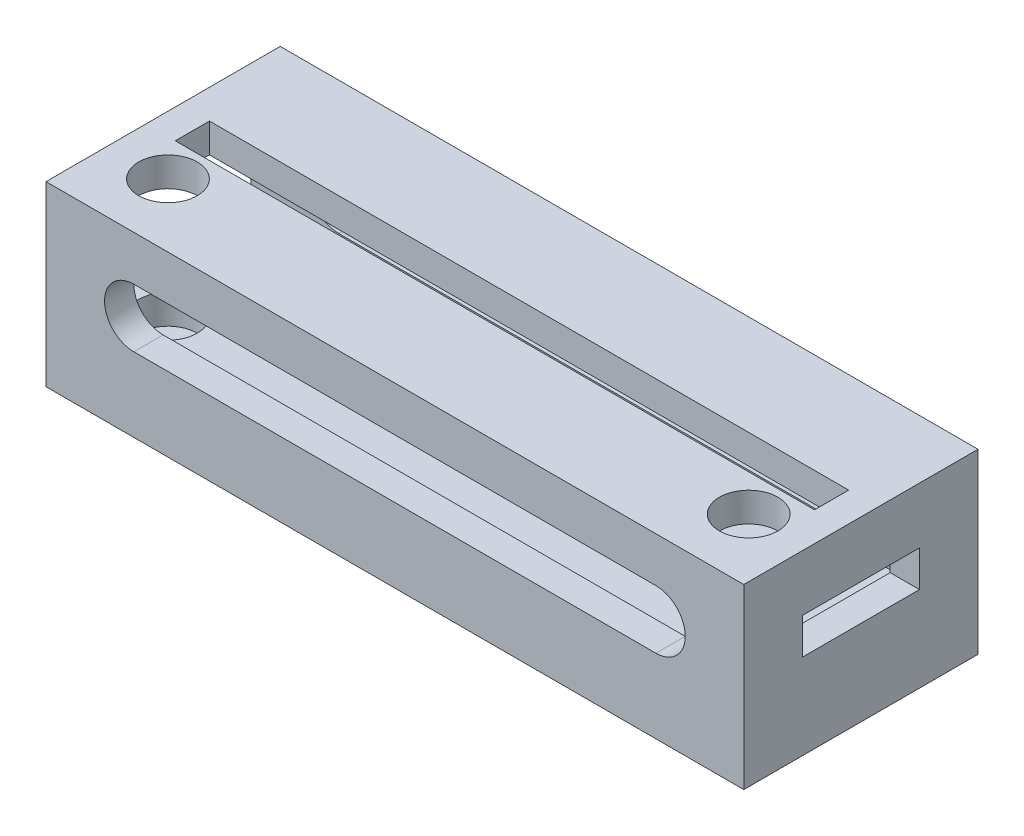
from build123d import *

# Parameters (mm, degrees)
SKETCH1_W            = 65.5
SKETCH1_H            = 9
SKETCH1_R            = 0.998395378
SKETCH1_R_2          = 1.243115981
BOSS_EXTRUDE1_DEPTH  = 6
SKETCH3_W            = 65.5
SKETCH3_H            = 6
BOSS_EXTRUDE2_DEPTH  = 10
SKETCH4_W            = 65.5
SKETCH4_H            = 6
BOSS_EXTRUDE3_DEPTH  = 2
SKETCH5_W            = 65.5
SKETCH5_H            = 3
BOSS_EXTRUDE4_DEPTH  = 9.2
SKETCH7_W            = 21
SKETCH7_H            = 15.2
BOSS_EXTRUDE6_DEPTH  = 3
SKETCH12_W           = 68.5
SKETCH12_H           = 15.2
BOSS_EXTRUDE10_DEPTH = 3
SKETCH13_W           = 24
SKETCH13_H           = 15.2
SKETCH13_W_2         = 12
SKETCH13_H_2         = 3.7
BOSS_EXTRUDE11_DEPTH = 3
CUT_EXTRUDE2_DEPTH   = 25
SKETCH11_W           = 18
SKETCH11_H           = 9.2
CUT_EXTRUDE4_DEPTH   = 3
SKETCH14_W           = 71.5
SKETCH14_H           = 24
BOSS_EXTRUDE12_DEPTH = 3
SKETCH15_W           = 65.5
SKETCH15_H           = 3.5
CUT_EXTRUDE5_DEPTH   = 3
SKETCH16_R           = 3
CUT_EXTRUDE6_DEPTH   = 15.2


with BuildPart() as part:
    # Sketch1 → Boss-Extrude1 (new body)
    with BuildSketch(Plane(origin=(0, 0, 0), x_dir=(1, 0, 0), z_dir=(0, 1, 0))):
        Rectangle(SKETCH1_W, SKETCH1_H)
        with Locations((-29.75, 0)):
            Circle(SKETCH1_R, mode=Mode.SUBTRACT)
        with Locations((29.75, 0)):
            Circle(SKETCH1_R_2, mode=Mode.SUBTRACT)
    extrude(amount=BOSS_EXTRUDE1_DEPTH)

    # Sketch3 → Boss-Extrude2 (add)
    with BuildSketch(Plane(origin=(0, 0, -4.5), x_dir=(-1, 0, 0), z_dir=(0, 0, -1))):
        with Locations((0, 3)):
            Rectangle(SKETCH3_W, SKETCH3_H)
    extrude(amount=BOSS_EXTRUDE2_DEPTH)

    # Sketch4 → Boss-Extrude3 (add)
    with BuildSketch(Plane.XY.offset(4.5)):
        with Locations((0, 3)):
            Rectangle(SKETCH4_W, SKETCH4_H)
    extrude(amount=BOSS_EXTRUDE3_DEPTH)

    # Sketch5 → Boss-Extrude4 (add)
    with BuildSketch(Plane(origin=(0, 6, 0), x_dir=(1, 0, 0), z_dir=(0, 1, 0))):
        with Locations((0, -5)):
            Rectangle(SKETCH5_W, SKETCH5_H)
    extrude(amount=BOSS_EXTRUDE4_DEPTH)

    # Sketch7 → Boss-Extrude6 (add)
    with BuildSketch(Plane.ZY.offset(32.75)):
        with Locations((-4, 7.6)):
            Rectangle(SKETCH7_W, SKETCH7_H)
    extrude(amount=BOSS_EXTRUDE6_DEPTH)

    # Sketch12 → Boss-Extrude10 (add)
    with BuildSketch(Plane(origin=(0, 0, -14.5), x_dir=(-1, 0, 0), z_dir=(0, 0, -1))):
        with Locations((1.5, 7.6)):
            Rectangle(SKETCH12_W, SKETCH12_H)
    extrude(amount=BOSS_EXTRUDE10_DEPTH)

    # Sketch13 → Boss-Extrude11 (add)
    with BuildSketch(Plane(origin=(32.75, 0, 0), x_dir=(0, 0, -1), z_dir=(1, 0, 0))):
        with Locations((5.5, 7.6)):
            Rectangle(SKETCH13_W, SKETCH13_H)
        with Locations((5.5, 10.6)):
            Rectangle(SKETCH13_W_2, SKETCH13_H_2, mode=Mode.SUBTRACT)
    extrude(amount=BOSS_EXTRUDE11_DEPTH)

    # Sketch6 → Cut-Extrude2 (cut, through all)
    with BuildSketch(Plane.XY.offset(6.5)):
        with BuildLine():
            ThreePointArc((-23.75, 10.6), (-24.628679656, 12.721320344), (-26.75, 13.6))
            Line((-26.75, 13.6), (-26.75, 7.6))
            ThreePointArc((-26.75, 7.6), (-24.628679656, 8.478679656), (-23.75, 10.6))
        make_face()
        with BuildLine():
            Line((-26.75, 7.6), (-26.75, 13.6))
            ThreePointArc((-26.75, 13.6), (-29.75, 10.6), (-26.75, 7.6))
        make_face()
        with BuildLine():
            ThreePointArc((29.75, 10.6), (28.871320344, 12.721320344), (26.75, 13.6))
            Line((26.75, 13.6), (26.75, 7.6))
            ThreePointArc((26.75, 7.6), (28.871320344, 8.478679656), (29.75, 10.6))
        make_face()
        with BuildLine():
            Line((26.75, 7.6), (26.75, 13.6))
            ThreePointArc((26.75, 13.6), (23.75, 10.6), (26.75, 7.6))
        make_face()
        with BuildLine():
            Line((26.75, 13.6), (-26.75, 13.6))
            ThreePointArc((-26.75, 13.6), (-24.628679656, 12.721320344), (-23.75, 10.6))
            ThreePointArc((-23.75, 10.6), (-24.628679656, 8.478679656), (-26.75, 7.6))
            Line((-26.75, 7.6), (26.75, 7.6))
            ThreePointArc((26.75, 7.6), (23.75, 10.6), (26.75, 13.6))
        make_face()
    extrude(amount=-CUT_EXTRUDE2_DEPTH, mode=Mode.SUBTRACT)

    # Sketch11 → Cut-Extrude4 (cut)
    with BuildSketch(Plane.ZY.offset(35.75)):
        with Locations((-5.5, 10.6)):
            Rectangle(SKETCH11_W, SKETCH11_H)
    extrude(amount=-CUT_EXTRUDE4_DEPTH, mode=Mode.SUBTRACT)

    # Sketch14 → Boss-Extrude12 (add)
    with BuildSketch(Plane(origin=(0, 15.2, 0), x_dir=(1, 0, 0), z_dir=(0, 1, 0))):
        with Locations((0, 5.5)):
            Rectangle(SKETCH14_W, SKETCH14_H)
    extrude(amount=BOSS_EXTRUDE12_DEPTH)

    # Sketch15 → Cut-Extrude5 (cut)
    with BuildSketch(Plane(origin=(0, 18.2, 0), x_dir=(1, 0, 0), z_dir=(0, 1, 0))):
        with Locations((0, 5.5)):
            Rectangle(SKETCH15_W, SKETCH15_H)
    extrude(amount=-CUT_EXTRUDE5_DEPTH, mode=Mode.SUBTRACT)

    # Sketch16 → Cut-Extrude6 (cut)
    with BuildSketch(Plane(origin=(0, 18.2, 0), x_dir=(1, 0, 0), z_dir=(0, 1, 0))):
        with Locations((-29.75, 0)):
            Circle(SKETCH16_R)
        with Locations((29.75, 0)):
            Circle(SKETCH16_R)
    extrude(amount=-CUT_EXTRUDE6_DEPTH, mode=Mode.SUBTRACT)


solid = part.part
